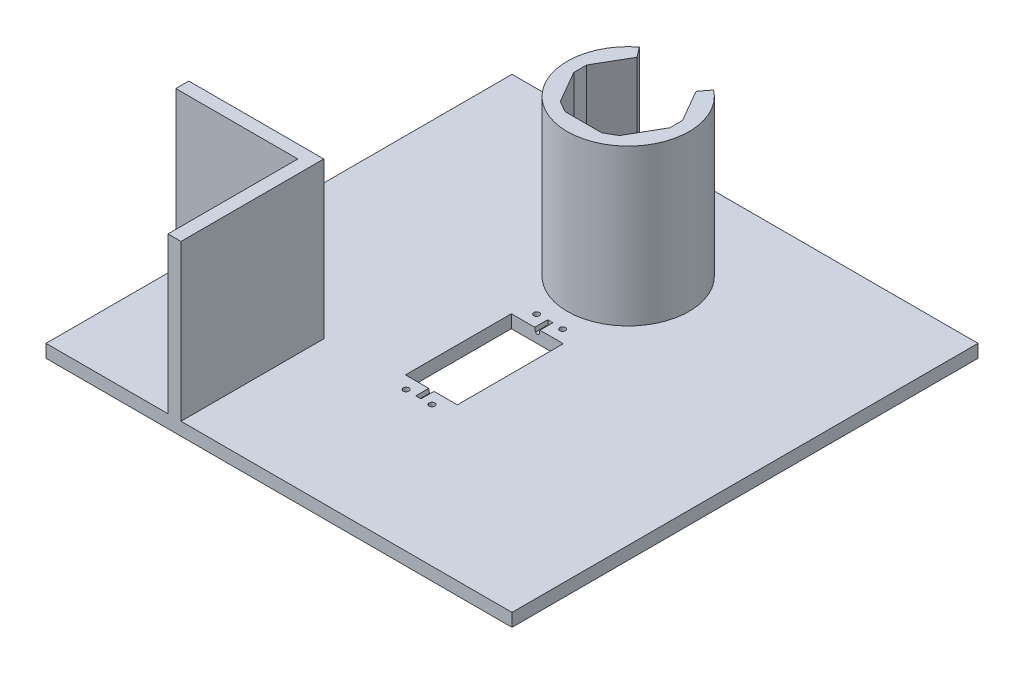
from build123d import *

# Parameters (mm, degrees)
SKETCH2_W           = 179.5
SKETCH2_H           = 179.5
BOSS_EXTRUDE1_DEPTH = 5
BOSS_EXTRUDE2_DEPTH = 60
SKETCH4_W           = 20
SKETCH4_H           = 40.8
SKETCH4_R           = 2.25
CUT_EXTRUDE1_DEPTH  = 5
CUT_EXTRUDE2_START  = -5
CUT_EXTRUDE2_DEPTH  = 50.8
SKETCH6_R           = 1.1
CUT_EXTRUDE3_DEPTH  = 5
SKETCH7_W           = 5
SKETCH7_H           = 50
BOSS_EXTRUDE3_DEPTH = 60


with BuildPart() as part:
    # Sketch2 → Boss-Extrude1 (new body)
    with BuildSketch(Plane(origin=(0, 0, 0), x_dir=(1, 0, 0), z_dir=(0, 1, 0))):
        Rectangle(SKETCH2_W, SKETCH2_H)
    extrude(amount=BOSS_EXTRUDE1_DEPTH)

    # Sketch3 → Boss-Extrude2 (add)
    with BuildSketch(Plane(origin=(0, 5, 0), x_dir=(1, 0, 0), z_dir=(0, 1, 0))):
        with BuildLine():
            Line((-14.325373702, 26.15370755), (-11.374207646, 29.984724331))
            Line((-11.374207646, 29.984724331), (-18.474207646, 42.282285065))
            Line((-18.474207646, 42.282285065), (-18.474207646, 47.217714935))
            Line((-18.474207646, 47.217714935), (-11.374207646, 59.515275669))
            Line((-11.374207646, 59.515275669), (-14.325373702, 63.34629245))
            ThreePointArc((-14.325373702, 63.34629245), (-23.474207646, 44.75), (-14.325373702, 26.15370755))
        make_face()
        with BuildLine():
            Line((11.374207646, 29.984724331), (14.325373702, 26.15370755))
            ThreePointArc((14.325373702, 26.15370755), (21.063181402, 34.387528584), (23.474207646, 44.75))
            ThreePointArc((23.474207646, 44.75), (21.063181402, 55.112471416), (14.325373702, 63.34629245))
            Line((14.325373702, 63.34629245), (11.374207646, 59.515275669))
            Line((11.374207646, 59.515275669), (18.474207646, 47.217714935))
            Line((18.474207646, 47.217714935), (18.474207646, 42.282285065))
            Line((18.474207646, 42.282285065), (11.374207646, 29.984724331))
        make_face()
        with BuildLine():
            Line((-7.1, 27.517009396), (-11.374207646, 29.984724331))
            Line((-11.374207646, 29.984724331), (-14.325373702, 26.15370755))
            ThreePointArc((-14.325373702, 26.15370755), (0, 21.275792354), (14.325373702, 26.15370755))
            Line((14.325373702, 26.15370755), (11.374207646, 29.984724331))
            Line((11.374207646, 29.984724331), (7.1, 27.517009396))
            Line((7.1, 27.517009396), (-7.1, 27.517009396))
        make_face()
    extrude(amount=BOSS_EXTRUDE2_DEPTH)

    # Sketch4 → Cut-Extrude1 (cut)
    with BuildSketch(Plane(origin=(0, 5, 0), x_dir=(1, 0, 0), z_dir=(0, 1, 0))):
        with Locations((0, -10.65)):
            Rectangle(SKETCH4_W, SKETCH4_H)
        with Locations((0, -0.25)):
            Circle(SKETCH4_R, mode=Mode.SUBTRACT)
        with Locations((0, -0.25)):
            Circle(SKETCH4_R)
    extrude(amount=-CUT_EXTRUDE1_DEPTH, mode=Mode.SUBTRACT)

    # Sketch5 → Cut-Extrude2 (cut)
    with BuildSketch(Plane.XY.offset(-9.75).offset(CUT_EXTRUDE2_START)):
        with BuildLine():
            Line((-1, 5), (-0.735509529, 3.5))
            ThreePointArc((-0.735509529, 3.5), (0, 3.177514378), (0.735509529, 3.5))
            Line((0.735509529, 3.5), (1, 5))
            Line((1, 5), (-1, 5))
        make_face()
    extrude(amount=CUT_EXTRUDE2_DEPTH, mode=Mode.SUBTRACT)

    # Sketch6 → Cut-Extrude3 (cut)
    with BuildSketch(Plane(origin=(0, 5, 0), x_dir=(1, 0, 0), z_dir=(0, 1, 0))):
        with Locations(Location((-5, 14.5, 0), (0, 0, 270))):
            Circle(SKETCH6_R)
        with Locations(Location((5, 14.5, 0), (0, 0, 270))):
            Circle(SKETCH6_R)
        with Locations(Location((5, -35.8, 0), (0, 0, 270))):
            Circle(SKETCH6_R)
        with Locations(Location((-5, -35.8, 0), (0, 0, 270))):
            Circle(SKETCH6_R)
    extrude(amount=-CUT_EXTRUDE3_DEPTH, mode=Mode.SUBTRACT)

    # Sketch7 → Boss-Extrude3 (add)
    with BuildSketch(Plane(origin=(0, 5, 0), x_dir=(1, 0, 0), z_dir=(0, 1, 0))):
        with Locations((-40.25, -64.75)):
            Rectangle(SKETCH7_W, SKETCH7_H)
        Polygon((-89.75, -34.75), (-89.75, -39.75), (-42.75, -39.75), (-37.75, -39.75), (-37.75, -34.75), align=None)
    extrude(amount=BOSS_EXTRUDE3_DEPTH)


solid = part.part
